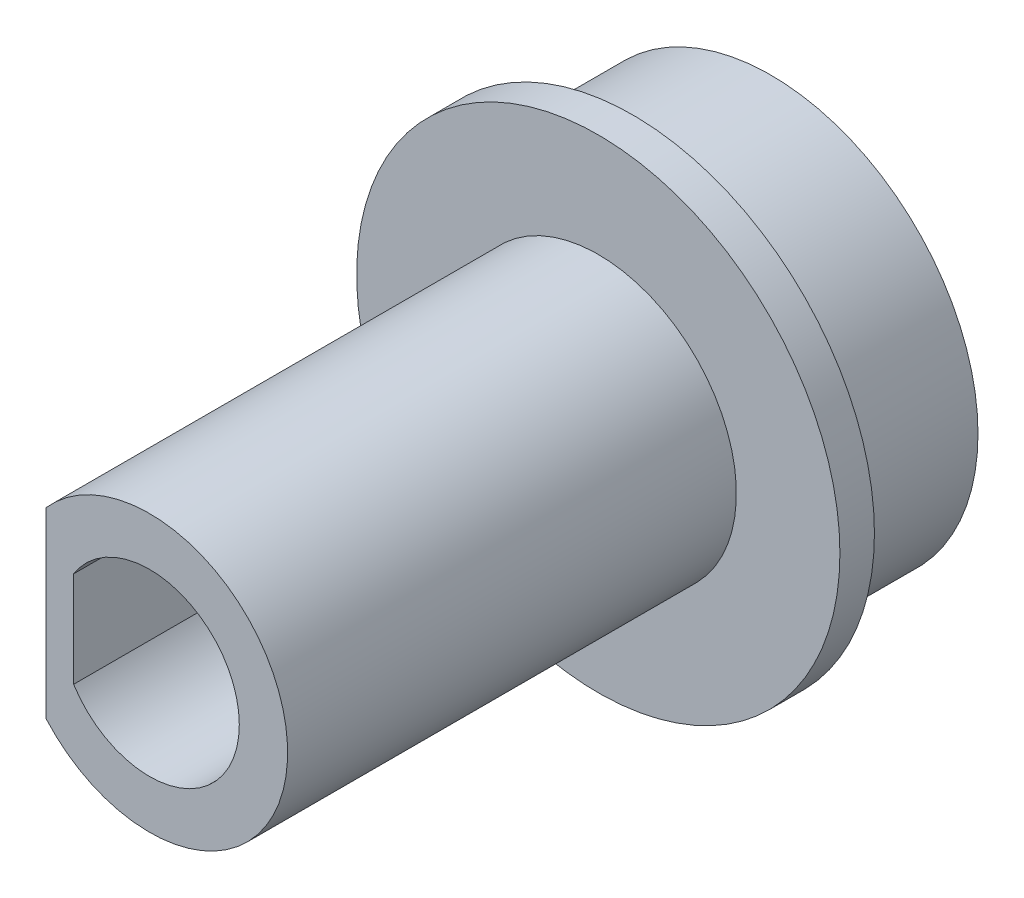
from build123d import *

# Parameters (mm, degrees)
SKETCH_1_R          = 6
EXTRUDE_1_DEPTH     = 5
SKETCH_7_R          = 7
EXTRUDE_6_DEPTH     = 1
EXTRUDE_2_DEPTH     = 13
CUT_EXTRUDE_1_DEPTH = 19


with BuildPart() as part:
    # 草图1 → 凸台-拉伸1 (new body)
    with BuildSketch(Plane.XY):
        Circle(SKETCH_1_R)
    extrude(amount=EXTRUDE_1_DEPTH)

    # 草图7 → 凸台-拉伸6 (add)
    with BuildSketch(Plane.XY.offset(5)):
        Circle(SKETCH_7_R)
    extrude(amount=-EXTRUDE_6_DEPTH)

    # 草图2 → 凸台-拉伸2 (add)
    with BuildSketch(Plane.XY.offset(5)):
        with BuildLine():
            ThreePointArc((4, 0), (1.414213562, 3.741657387), (-3, 2.645751311))
            Line((-3, 2.645751311), (-3, -2.645751311))
            ThreePointArc((-3, -2.645751311), (1.414213562, -3.741657387), (4, 0))
        make_face()
    extrude(amount=EXTRUDE_2_DEPTH)

    # 草图8 → 切除-拉伸1 (cut, through all)
    with BuildSketch(Plane.XY):
        with BuildLine():
            ThreePointArc((2.6, 0), (0.721110255, 2.497999199), (-2.2, 1.385640646))
            Line((-2.2, 1.385640646), (-2.2, -1.385640646))
            ThreePointArc((-2.2, -1.385640646), (0.721110255, -2.497999199), (2.6, 0))
        make_face()
    extrude(amount=CUT_EXTRUDE_1_DEPTH, mode=Mode.SUBTRACT)


solid = part.part
